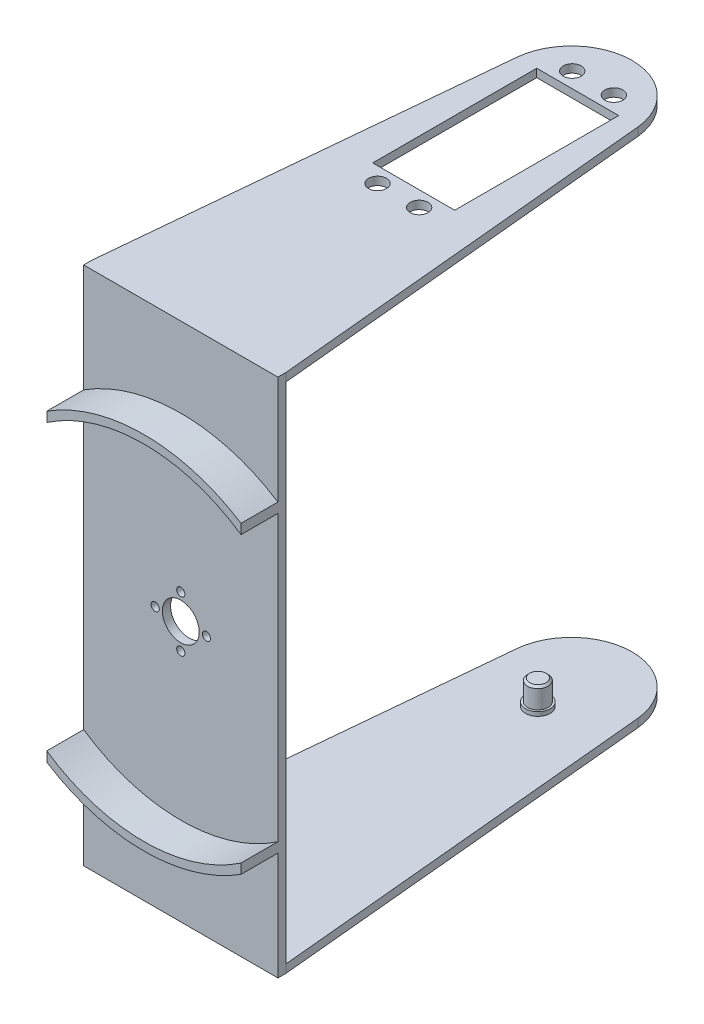
from build123d import *

# Parameters (mm, degrees)
SKETCH1_R                = 2.1844
BOSS_EXTRUDE1_DEPTH      = 2
BOSS_EXTRUDE2_DEPTH      = 2
BOSS_EXTRUDE2_DEPTH_BACK = 122.9409
SKETCH1_3_W              = 47.380920583
SKETCH1_3_H              = 2
BOSS_EXTRUDE3_DEPTH      = 2
SKETCH2_3_R              = 3
SKETCH2_3_R_2            = 2.5
BOSS_EXTRUDE4_DEPTH      = 1
SKETCH2_4_R              = 2.5
BOSS_EXTRUDE5_DEPTH      = 6
CHAMFER1_SIZE            = 0.5
SKETCH3_R                = 4.5
SKETCH3_R_2              = 1
CUT_EXTRUDE1_DEPTH       = 10
BOSS_EXTRUDE6_DEPTH      = 8.99804


with BuildPart() as part:
    # Sketch1 → Boss-Extrude1 (new body)
    with BuildSketch(Plane(origin=(0, 0, 0), x_dir=(1, 0, 0), z_dir=(0, 1, 0))):
        with BuildLine():
            ThreePointArc((14.738721003, 0), (0, 13.282171548), (-14.738721003, 0))
            Line((-14.738721003, 0), (-23.700563463, -94.809011723))
            Line((-23.700563463, -94.809011723), (23.68035712, -94.809011723))
            Line((23.68035712, -94.809011723), (14.738721003, 0))
        make_face()
        with BuildLine():
            ThreePointArc((-6.524844791, -45.395600002), (-5.978744791, -41.766355211), (-2.8956, -43.757300002))
            ThreePointArc((-2.8956, -43.757300002), (-3.089055209, -44.656044793), (-3.635155209, -45.395600002))
            ThreePointArc((-3.635155209, -45.395600002), (-5.08, -45.941700002), (-6.524844791, -45.395600002))
        make_face(mode=Mode.SUBTRACT)
        with Locations((5.08, -43.757300002)):
            Circle(SKETCH1_R, mode=Mode.SUBTRACT)
        with Locations((-5.08, 3.740699998)):
            Circle(SKETCH1_R, mode=Mode.SUBTRACT)
        Polygon((-10, 0), (0, 0), (10, 0), (10, -40), (-10, -40), align=None, mode=Mode.SUBTRACT)
        with Locations((5.08, 3.740699998)):
            Circle(SKETCH1_R, mode=Mode.SUBTRACT)
    extrude(amount=BOSS_EXTRUDE1_DEPTH)

    # Sketch1_3 → Boss-Extrude2 (add, two sides: drawn at the far end of the back side and taken through both)
    with BuildSketch(Plane(origin=(0, 0, 0), x_dir=(1, 0, 0), z_dir=(0, 1, 0)).offset(-BOSS_EXTRUDE2_DEPTH_BACK)):
        with Locations((-0.010103172, -95.809011723)):
            Rectangle(SKETCH1_3_W, SKETCH1_3_H)
    extrude(amount=BOSS_EXTRUDE2_DEPTH + BOSS_EXTRUDE2_DEPTH_BACK)

    # Sketch2 → Boss-Extrude3 (add)
    with BuildSketch(Plane.XZ.offset(122.9409)):
        with BuildLine():
            ThreePointArc((-14.758927346, 0), (-0.020206343, -13.282171548), (14.71851466, 0))
            Line((14.71851466, 0), (23.68035712, 94.809011723))
            Line((23.68035712, 94.809011723), (23.68035712, 96.809011723))
            Line((23.68035712, 96.809011723), (-23.700563463, 96.809011723))
            Line((-23.700563463, 96.809011723), (-23.700563463, 94.809011723))
            Line((-23.700563463, 94.809011723), (-14.758927346, 0))
        make_face()
    extrude(amount=BOSS_EXTRUDE3_DEPTH)

    # Sketch2_3 → Boss-Extrude4 (add)
    with BuildSketch(Plane.XZ.offset(122.9409)):
        with Locations((0, 9.721300002)):
            Circle(SKETCH2_3_R)
        with Locations((0, 9.721300002)):
            Circle(SKETCH2_3_R_2, mode=Mode.SUBTRACT)
    extrude(amount=-BOSS_EXTRUDE4_DEPTH)

    # Sketch2_4 → Boss-Extrude5 (add)
    with BuildSketch(Plane.XZ.offset(122.9409)):
        with Locations((0, 9.721300002)):
            Circle(SKETCH2_4_R)
    extrude(amount=-BOSS_EXTRUDE5_DEPTH)

    # Chamfer1
    chamfer1_edges = [part.edges().sort_by_distance(p)[0] for p in [
        (-2.5, -116.9409, 9.721300002),
    ]]
    chamfer(chamfer1_edges, length=CHAMFER1_SIZE)

    # Sketch3 → Cut-Extrude1 (cut)
    with BuildSketch(Plane(origin=(0, 0, 94.809011723), x_dir=(-1, 0, 0), z_dir=(0, 0, -1))):
        with Locations((0.010103172, -61.47045)):
            Circle(SKETCH3_R)
        with Locations((6.260103172, -61.47045)):
            Circle(SKETCH3_R_2)
        with Locations((0.010103172, -67.72045)):
            Circle(SKETCH3_R_2)
        with Locations((-6.239896828, -61.47045)):
            Circle(SKETCH3_R_2)
        with Locations((0.010103172, -55.22045)):
            Circle(SKETCH3_R_2)
    extrude(amount=-CUT_EXTRUDE1_DEPTH, mode=Mode.SUBTRACT)

    # Sketch4 → Boss-Extrude6 (add)
    with BuildSketch(Plane.XY.offset(96.809011723)):
        with BuildLine():
            ThreePointArc((-23.700563463, -98.548234335), (-0.010103172, -105.47045), (23.68035712, -98.548234335))
            Line((23.68035712, -98.548234335), (23.68035712, -96.151310589))
            ThreePointArc((23.68035712, -96.151310589), (-0.010103172, -103.47045), (-23.700563463, -96.151310589))
            Line((-23.700563463, -96.151310589), (-23.700563463, -98.548234335))
        make_face()
        with BuildLine():
            ThreePointArc((-23.700563463, -26.789589411), (-0.010103172, -19.47045), (23.68035712, -26.789589411))
            Line((23.68035712, -26.789589411), (23.68035712, -24.392665665))
            ThreePointArc((23.68035712, -24.392665665), (-0.010103172, -17.47045), (-23.700563463, -24.392665665))
            Line((-23.700563463, -24.392665665), (-23.700563463, -26.789589411))
        make_face()
    extrude(amount=BOSS_EXTRUDE6_DEPTH)


solid = part.part
